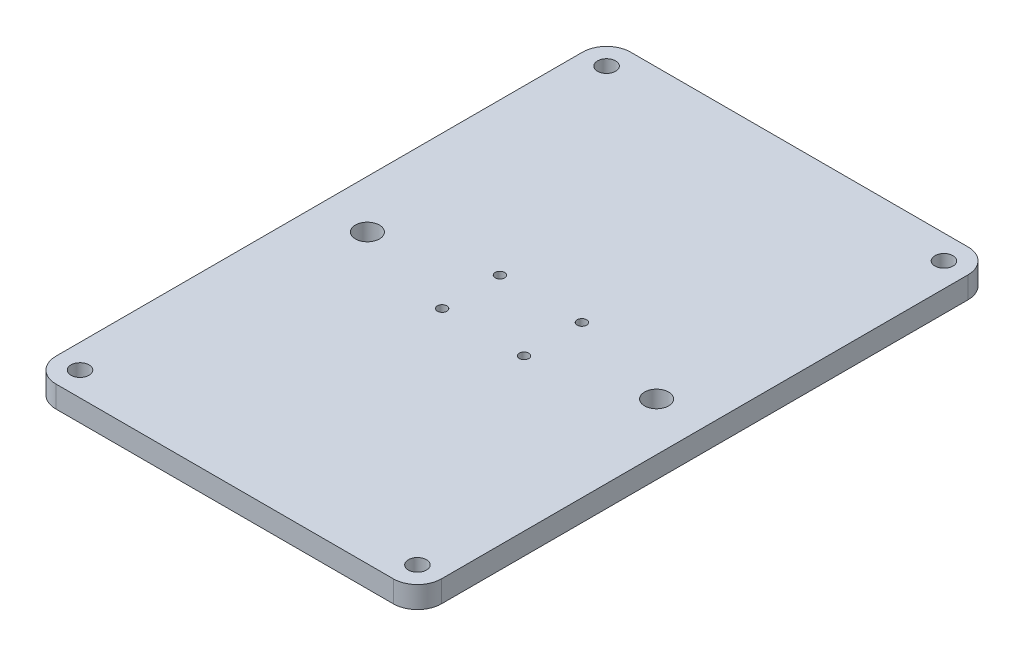
from build123d import *

# Parameters (mm, degrees)
SKETCH1_R           = 1.25
SKETCH1_R_2         = 3.175
SKETCH1_R_3         = 2.38125
BOSS_EXTRUDE1_DEPTH = 5.715


with BuildPart() as part:
    # Sketch1 → Boss-Extrude1 (new body)
    with BuildSketch(Plane(origin=(0, -17.549974667, 0), x_dir=(1, 0, 0), z_dir=(0, 1, 0))):
        with BuildLine():
            Line((-44.45, -75.719872981), (44.45, -75.719872981))
            ThreePointArc((44.45, -75.719872981), (48.940128061, -73.860001042), (50.8, -69.369872981))
            Line((50.8, -69.369872981), (50.8, 69.369872981))
            ThreePointArc((50.8, 69.369872981), (48.940128061, 73.860001042), (44.45, 75.719872981))
            Line((44.45, 75.719872981), (-44.45, 75.719872981))
            ThreePointArc((-44.45, 75.719872981), (-48.940128061, 73.860001042), (-50.8, 69.369872981))
            Line((-50.8, 69.369872981), (-50.8, -69.369872981))
            ThreePointArc((-50.8, -69.369872981), (-48.940128061, -73.860001042), (-44.45, -75.719872981))
        make_face()
        with Locations((-10.795, 7.62)):
            Circle(SKETCH1_R, mode=Mode.SUBTRACT)
        with Locations((-10.795, -7.62)):
            Circle(SKETCH1_R, mode=Mode.SUBTRACT)
        with Locations((10.795, -7.62)):
            Circle(SKETCH1_R, mode=Mode.SUBTRACT)
        with Locations((10.795, 7.62)):
            Circle(SKETCH1_R, mode=Mode.SUBTRACT)
        with Locations((38.1, 0)):
            Circle(SKETCH1_R_2, mode=Mode.SUBTRACT)
        with Locations((-38.1, 0)):
            Circle(SKETCH1_R_2, mode=Mode.SUBTRACT)
        with Locations((44.45, 69.369872981)):
            Circle(SKETCH1_R_3, mode=Mode.SUBTRACT)
        with Locations((-44.45, 69.369872981)):
            Circle(SKETCH1_R_3, mode=Mode.SUBTRACT)
        with Locations((-44.45, -69.369872981)):
            Circle(SKETCH1_R_3, mode=Mode.SUBTRACT)
        with Locations((44.45, -69.369872981)):
            Circle(SKETCH1_R_3, mode=Mode.SUBTRACT)
    extrude(amount=BOSS_EXTRUDE1_DEPTH)


solid = part.part
